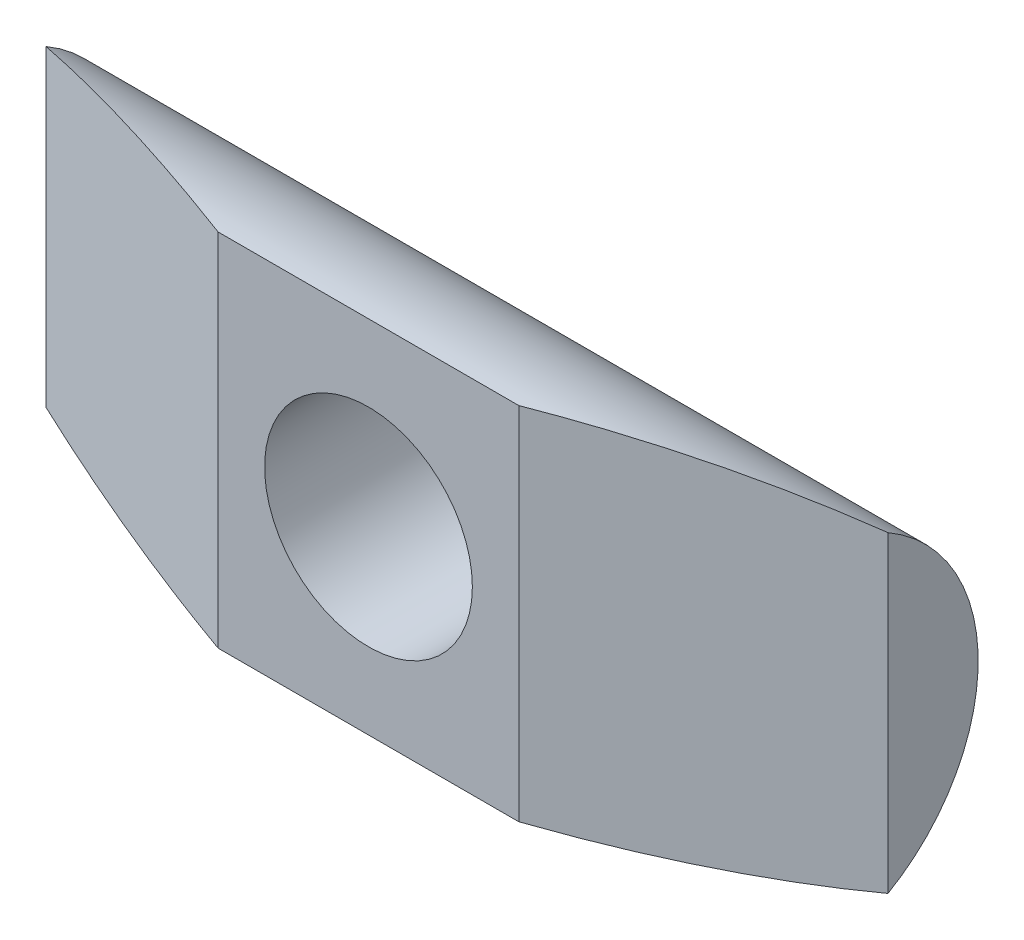
from build123d import *

# Parameters (mm, degrees)
EXTRUDE1_START           = -14
SKETCH1_R                = 6
EXTRUDE1_DEPTH           = 28
EXTRUDE2_DEPTH           = 20
EXTRUDE2_DEPTH_BACK      = 20
F_5_16_24_TAPPED_HOLE1_D = 6.9088


with BuildPart() as part:
    # Sketch1 → Extrude1 (new body)
    with BuildSketch(Plane(origin=(0, 0, 0), x_dir=(0, 0, -1), z_dir=(1, 0, 0)).offset(EXTRUDE1_START)):
        Circle(SKETCH1_R)
    extrude(amount=EXTRUDE1_DEPTH)

    # Sketch2 → Extrude2 (cut, two sides)
    with BuildSketch(Plane(origin=(0, 0, 0), x_dir=(1, 0, 0), z_dir=(0, 1, 0))) as extrude2_sk:
        Polygon((-5, -0.275732108), (5, -0.275732108), (14, 3), (25.458166387, 3), (25.458166387, -16.52435343), (-25.590688577, -16.52435343), (-25.590688577, 3), (-14, 3), align=None)
    extrude(amount=EXTRUDE2_DEPTH, mode=Mode.SUBTRACT)
    extrude(extrude2_sk.sketch, amount=-EXTRUDE2_DEPTH_BACK, mode=Mode.SUBTRACT)

    # 5_16-24 Tapped Hole1 (through all)
    with Locations(Plane.XY.offset(0.275732108)):
        with Locations((0, 0)):
            Hole(F_5_16_24_TAPPED_HOLE1_D / 2)


solid = part.part
